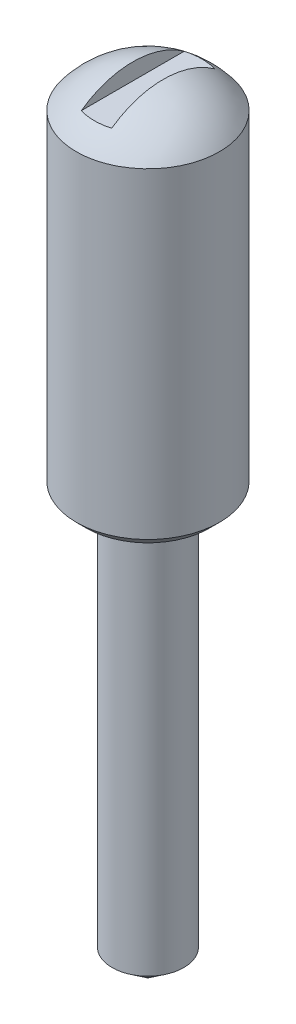
from build123d import *

# Parameters (mm, degrees)
DOME_1_FACE_RADIUS       = 4
DOME_1_HEIGHT            = 2
SKETCH_3_W               = 1.7
SKETCH_3_H               = 10
CUT_EXTRUDE_1_DEPTH      = 5
CUT_EXTRUDE_1_DEPTH_BACK = 5
CHAMFER_1_SIZE           = 0.5545


with BuildPart() as part:
    # Sketch 2 → Revolve 1 (revolve)
    with BuildSketch(Plane.XY):
        Polygon((0, 0), (2, 1.5), (2, 23.5), (4, 23.5), (4, 42), (0, 42), align=None)
    revolve(axis=Axis((0, 42, 0), (0, -1, 0)))

    # Dome 1: a dome of height H over a round flat face of radius A is a cap of a sphere of radius (A * A + H * H) / (2 * H)
    dome_1_r = (DOME_1_FACE_RADIUS * DOME_1_FACE_RADIUS + DOME_1_HEIGHT * DOME_1_HEIGHT) / (2 * DOME_1_HEIGHT)
    dome_1_base = Plane((0, 42, 0), z_dir=(0, 1, 0))
    with Locations(dome_1_base.offset(DOME_1_HEIGHT - dome_1_r)):
        dome_1_ball = Sphere(dome_1_r, mode=Mode.PRIVATE)
    add(split(dome_1_ball, bisect_by=dome_1_base, keep=Keep.TOP, mode=Mode.PRIVATE))

    # Sketch 3 → Cut-Extrude 1 (cut, two sides)
    with BuildSketch(Plane.XY) as cut_extrude_1_sk:
        with Locations((0, 48)):
            Rectangle(SKETCH_3_W, SKETCH_3_H)
    extrude(amount=CUT_EXTRUDE_1_DEPTH, mode=Mode.SUBTRACT)
    extrude(cut_extrude_1_sk.sketch, amount=-CUT_EXTRUDE_1_DEPTH_BACK, mode=Mode.SUBTRACT)

    # Chamfer 1
    chamfer_1_edges = [part.edges().sort_by_distance(p)[0] for p in [
        (-4, 23.5, 0),
    ]]
    chamfer(chamfer_1_edges, length=CHAMFER_1_SIZE)


solid = part.part
